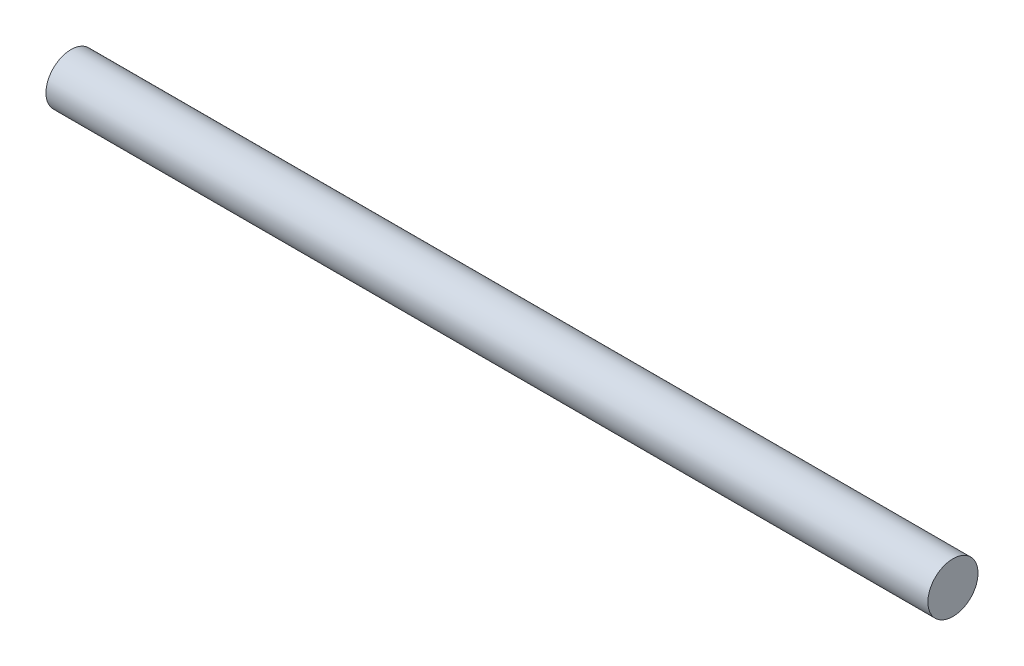
from build123d import *

# Parameters (mm, degrees)
SKETCH2_R           = 5
BOSS_EXTRUDE1_DEPTH = 88


with BuildPart() as part:
    # Sketch2 → Boss-Extrude1 (new body, symmetric)
    with BuildSketch(Plane(origin=(0, 0, 0), x_dir=(0, 0, -1), z_dir=(1, 0, 0))):
        Circle(SKETCH2_R)
    extrude(amount=BOSS_EXTRUDE1_DEPTH, both=True)


solid = part.part
